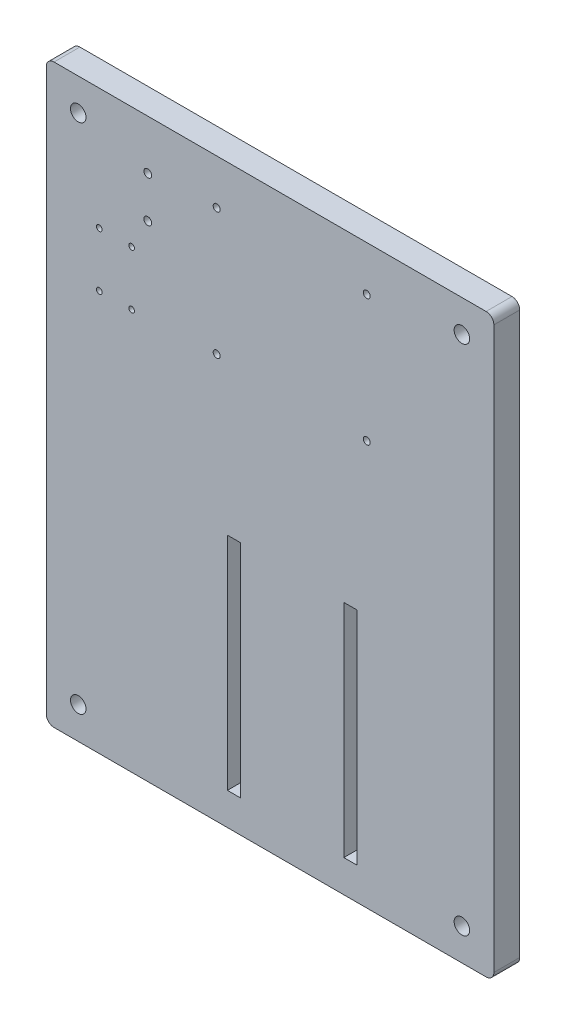
from build123d import *

# Parameters (mm, degrees)
CROQUIS1_R              = 3
CROQUIS1_W              = 5
CROQUIS1_H              = 85.41873638
CROQUIS1_W_2            = 23.862
CROQUIS1_H_2            = 25
CROQUIS1_W_3            = 15
CROQUIS1_H_3            = 20
CROQUIS1_R_2            = 1.5
CROQUIS1_R_3            = 1.1
CROQUIS1_R_4            = 1.35
SALIENTE_EXTRUIR1_DEPTH = 10


with BuildPart() as part:
    # Croquis1 → Saliente-Extruir1 (new body)
    with BuildSketch(Plane.XY):
        with BuildLine():
            ThreePointArc((83.492, 111.366), (85.613320344, 110.487320344), (86.492, 108.366))
            Line((86.492, 108.366), (86.492, -108.366))
            ThreePointArc((86.492, -108.366), (85.613320344, -110.487320344), (83.492, -111.366))
            Line((83.492, -111.366), (-83.492, -111.366))
            ThreePointArc((-83.492, -111.366), (-85.613320344, -110.487320344), (-86.492, -108.366))
            Line((-86.492, -108.366), (-86.492, 108.366))
            ThreePointArc((-86.492, 108.366), (-85.613320344, 110.487320344), (-83.492, 111.366))
            Line((-83.492, 111.366), (83.492, 111.366))
        make_face()
        with Locations((74.136, 98.992)):
            Circle(CROQUIS1_R, mode=Mode.SUBTRACT)
        with Locations((-74.136, 98.992)):
            Circle(CROQUIS1_R, mode=Mode.SUBTRACT)
        with Locations((74.136, -98.992)):
            Circle(CROQUIS1_R, mode=Mode.SUBTRACT)
        with Locations((-74.136, -98.992)):
            Circle(CROQUIS1_R, mode=Mode.SUBTRACT)
        with BuildLine():
            ThreePointArc((55.881809493, 42.260900296), (58.356683228, 43.286026562), (59.381809493, 45.760900296))
            Line((59.381809493, 45.760900296), (59.381809493, 94.012))
            ThreePointArc((59.381809493, 94.012), (58.356683228, 96.486873734), (55.881809493, 97.512))
            Line((55.881809493, 97.512), (-22.118190507, 97.512))
            ThreePointArc((-22.118190507, 97.512), (-24.593064241, 96.486873734), (-25.618190507, 94.012))
            Line((-25.618190507, 94.012), (-25.618190507, 45.760900296))
            ThreePointArc((-25.618190507, 45.760900296), (-24.593064241, 43.286026562), (-22.118190507, 42.260900296))
            Line((-22.118190507, 42.260900296), (55.881809493, 42.260900296))
        make_face(mode=Mode.SUBTRACT)
        with Locations((31.008, -56.19736819)):
            Rectangle(CROQUIS1_W, CROQUIS1_H, mode=Mode.SUBTRACT)
        with Locations((-13.992, -56.19736819)):
            Rectangle(CROQUIS1_W, CROQUIS1_H, mode=Mode.SUBTRACT)
        with Locations((-56.067, 54.012)):
            Rectangle(CROQUIS1_W_2, CROQUIS1_H_2, mode=Mode.SUBTRACT)
        with Locations((-52.84846771, 84.244)):
            Rectangle(CROQUIS1_W_3, CROQUIS1_H_3, mode=Mode.SUBTRACT)
        with Locations((-52.84846771, 84.244)):
            Rectangle(CROQUIS1_W_3, CROQUIS1_H_3)
        with Locations((-47.26410382, 92.23269661)):
            Circle(CROQUIS1_R_2, mode=Mode.SUBTRACT)
        with Locations((-47.26410382, 76.25530339)):
            Circle(CROQUIS1_R_2, mode=Mode.SUBTRACT)
        with Locations((-56.067, 54.012)):
            Rectangle(CROQUIS1_W_2, CROQUIS1_H_2)
        with Locations((-53.498, 64.512)):
            Circle(CROQUIS1_R_3, mode=Mode.SUBTRACT)
        with Locations((-53.498, 43.512)):
            Circle(CROQUIS1_R_3, mode=Mode.SUBTRACT)
        with Locations((-65.998, 43.512)):
            Circle(CROQUIS1_R_3, mode=Mode.SUBTRACT)
        with Locations((-65.998, 64.512)):
            Circle(CROQUIS1_R_3, mode=Mode.SUBTRACT)
        with BuildLine():
            Line((-22.118190507, 42.260900296), (55.881809493, 42.260900296))
            ThreePointArc((55.881809493, 42.260900296), (58.356683228, 43.286026562), (59.381809493, 45.760900296))
            Line((59.381809493, 45.760900296), (59.381809493, 94.012))
            ThreePointArc((59.381809493, 94.012), (58.356683228, 96.486873734), (55.881809493, 97.512))
            Line((55.881809493, 97.512), (-22.118190507, 97.512))
            ThreePointArc((-22.118190507, 97.512), (-24.593064241, 96.486873734), (-25.618190507, 94.012))
            Line((-25.618190507, 94.012), (-25.618190507, 45.760900296))
            ThreePointArc((-25.618190507, 45.760900296), (-24.593064241, 43.286026562), (-22.118190507, 42.260900296))
        make_face()
        with Locations((-20.636, 94.012)):
            Circle(CROQUIS1_R_4, mode=Mode.SUBTRACT)
        with Locations((37.364, 94.012)):
            Circle(CROQUIS1_R_4, mode=Mode.SUBTRACT)
        with Locations((37.364, 45.012)):
            Circle(CROQUIS1_R_4, mode=Mode.SUBTRACT)
        with Locations((-20.636, 45.012)):
            Circle(CROQUIS1_R_4, mode=Mode.SUBTRACT)
    extrude(amount=SALIENTE_EXTRUIR1_DEPTH)


solid = part.part
